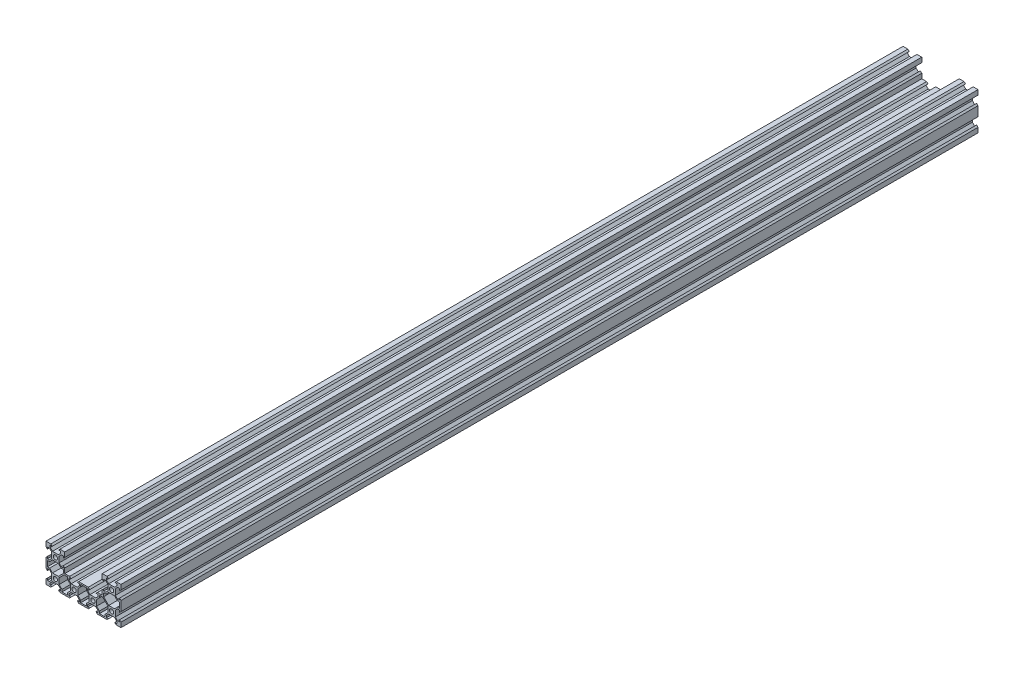
from build123d import *

# Parameters (mm, degrees)
SKETCH2_R           = 2.25
BOSS_EXTRUDE1_DEPTH = 914.4


with BuildPart() as part:
    # Sketch2 → Boss-Extrude1 (new body)
    with BuildSketch(Plane.XY):
        Polygon((-5.125, -10), (5.125, -10), (6.625, -8.5), (4.5, -8.5), (4.5, -6.383883476), (6.883883476, -4), (13.116116524, -4), (15.5, -6.383883476), (15.5, -8.5), (13.375, -8.5), (14.875, -10), (25.125, -10), (26.625, -8.5), (24.5, -8.5), (24.5, -6.383883476), (26.883883476, -4), (33.116116524, -4), (35.5, -6.383883476), (35.5, -8.5), (33.375, -8.5), (34.875, -10), (40, -10), (40, -4.875), (38.5, -3.375), (38.5, -5.5), (36.383883476, -5.5), (34, -3.116116524), (34, 3.116116524), (36.383883476, 5.5), (38.5, 5.5), (38.5, 3.375), (40, 4.875), (40, 15.125), (38.5, 16.625), (38.5, 14.5), (36.383883476, 14.5), (34, 16.883883476), (34, 23.116116524), (36.383883476, 25.5), (38.5, 25.5), (38.5, 23.375), (40, 24.875), (40, 30), (34.875, 30), (33.375, 28.5), (35.5, 28.5), (35.5, 26.383883476), (33.116116524, 24), (26.883883476, 24), (24.5, 26.383883476), (24.5, 28.5), (26.625, 28.5), (25.125, 30), (20, 30), (20, 24.875), (21.5, 23.375), (21.5, 25.5), (23.616116524, 25.5), (26, 23.116116524), (26, 16.883883476), (23.616116524, 14.5), (21.5, 14.5), (21.5, 16.625), (20, 15.125), (20, 10), (14.875, 10), (13.375, 8.5), (15.5, 8.5), (15.5, 6.383883476), (13.116116524, 4), (6.883883476, 4), (4.5, 6.383883476), (4.5, 8.5), (6.625, 8.5), (5.125, 10), (-5.125, 10), (-6.625, 8.5), (-4.5, 8.5), (-4.5, 6.383883476), (-6.883883476, 4), (-13.116116524, 4), (-15.5, 6.383883476), (-15.5, 8.5), (-13.375, 8.5), (-14.875, 10), (-20, 10), (-20, 15.125), (-21.5, 16.625), (-21.5, 14.5), (-23.616116524, 14.5), (-26, 16.883883476), (-26, 23.116116524), (-23.616116524, 25.5), (-21.5, 25.5), (-21.5, 23.375), (-20, 24.875), (-20, 30), (-25.125, 30), (-26.625, 28.5), (-24.5, 28.5), (-24.5, 26.383883476), (-26.883883476, 24), (-33.116116524, 24), (-35.5, 26.383883476), (-35.5, 28.5), (-33.375, 28.5), (-34.875, 30), (-40, 30), (-40, 24.875), (-38.5, 23.375), (-38.5, 25.5), (-36.383883476, 25.5), (-34, 23.116116524), (-34, 16.883883476), (-36.383883476, 14.5), (-38.5, 14.5), (-38.5, 16.625), (-40, 15.125), (-40, 4.875), (-38.5, 3.375), (-38.5, 5.5), (-36.383883476, 5.5), (-34, 3.116116524), (-34, -3.116116524), (-36.383883476, -5.5), (-38.5, -5.5), (-38.5, -3.375), (-40, -4.875), (-40, -10), (-34.875, -10), (-33.375, -8.5), (-35.5, -8.5), (-35.5, -6.383883476), (-33.116116524, -4), (-26.883883476, -4), (-24.5, -6.383883476), (-24.5, -8.5), (-26.625, -8.5), (-25.125, -10), (-14.875, -10), (-13.375, -8.5), (-15.5, -8.5), (-15.5, -6.383883476), (-13.116116524, -4), (-6.883883476, -4), (-4.5, -6.383883476), (-4.5, -8.5), (-6.625, -8.5), align=None)
        with Locations((-30, 0)):
            Circle(SKETCH2_R, mode=Mode.SUBTRACT)
        Polygon((-26, -3.116116524), (-26, 3.109045456), (-20.609045456, 8.5), (-17, 8.5), (-17, 6.116116524), (-14, 3.116116524), (-14, -3.116116524), (-17, -6.116116524), (-17, -8.5), (-23, -8.5), (-23, -6.116116524), align=None, mode=Mode.SUBTRACT)
        with Locations((-10, 0)):
            Circle(SKETCH2_R, mode=Mode.SUBTRACT)
        Polygon((-6, -3.116116524), (-6, 3.116116524), (-3, 6.116116524), (-3, 8.5), (3, 8.5), (3, 6.116116524), (6, 3.116116524), (6, -3.116116524), (3, -6.116116524), (3, -8.5), (-3, -8.5), (-3, -6.116116524), align=None, mode=Mode.SUBTRACT)
        with Locations((10, 0)):
            Circle(SKETCH2_R, mode=Mode.SUBTRACT)
        Polygon((26, 3.109045456), (26, -3.116116524), (23, -6.116116524), (23, -8.5), (17, -8.5), (17, -6.116116524), (14, -3.116116524), (14, 3.116116524), (17, 6.116116524), (17, 8.5), (20.609045456, 8.5), align=None, mode=Mode.SUBTRACT)
        with Locations((30, 0)):
            Circle(SKETCH2_R, mode=Mode.SUBTRACT)
        Polygon((-36.116116524, 13), (-33.116116524, 16), (-26.883883476, 16), (-23.883883476, 13), (-21.5, 13), (-21.5, 9.390954544), (-26.890954544, 4), (-33.116116524, 4), (-36.116116524, 7), (-38.5, 7), (-38.5, 13), align=None, mode=Mode.SUBTRACT)
        with Locations((-30, 20)):
            Circle(SKETCH2_R, mode=Mode.SUBTRACT)
        Polygon((33.116116524, 16), (36.116116524, 13), (38.5, 13), (38.5, 7), (36.116116524, 7), (33.116116524, 4), (26.890954544, 4), (21.5, 9.390954544), (21.5, 13), (23.883883476, 13), (26.883883476, 16), align=None, mode=Mode.SUBTRACT)
        with Locations((30, 20)):
            Circle(SKETCH2_R, mode=Mode.SUBTRACT)
    extrude(amount=BOSS_EXTRUDE1_DEPTH)


solid = part.part
